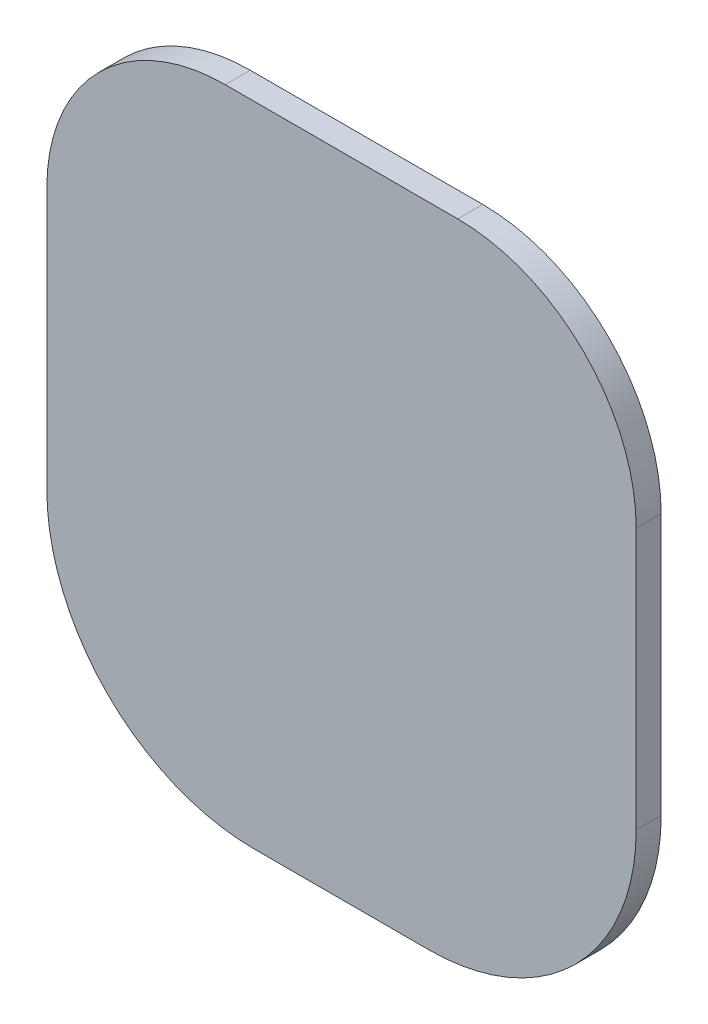
from build123d import *

# Parameters (mm, degrees)
BOSS_EXTRUDE1_DEPTH = 4.3


with BuildPart() as part:
    # Sketch3 → Boss-Extrude1 (new body)
    with BuildSketch(Plane.XY):
        with BuildLine():
            Line((-20, 47.7), (20, 47.7))
            ThreePointArc((20, 47.7), (41.708178182, 38.708178182), (50.7, 17))
            Line((50.7, 17), (50.7, -28))
            ThreePointArc((50.7, -28), (40.243712088, -53.243712088), (15, -63.7))
            Line((15, -63.7), (0.5, -63.7))
            Line((0.5, -63.7), (-0.5, -63.7))
            Line((-0.5, -63.7), (-15, -63.7))
            ThreePointArc((-15, -63.7), (-40.243712088, -53.243712088), (-50.7, -28))
            Line((-50.7, -28), (-50.7, 17))
            ThreePointArc((-50.7, 17), (-41.708178182, 38.708178182), (-20, 47.7))
        make_face()
    extrude(amount=BOSS_EXTRUDE1_DEPTH)


solid = part.part
